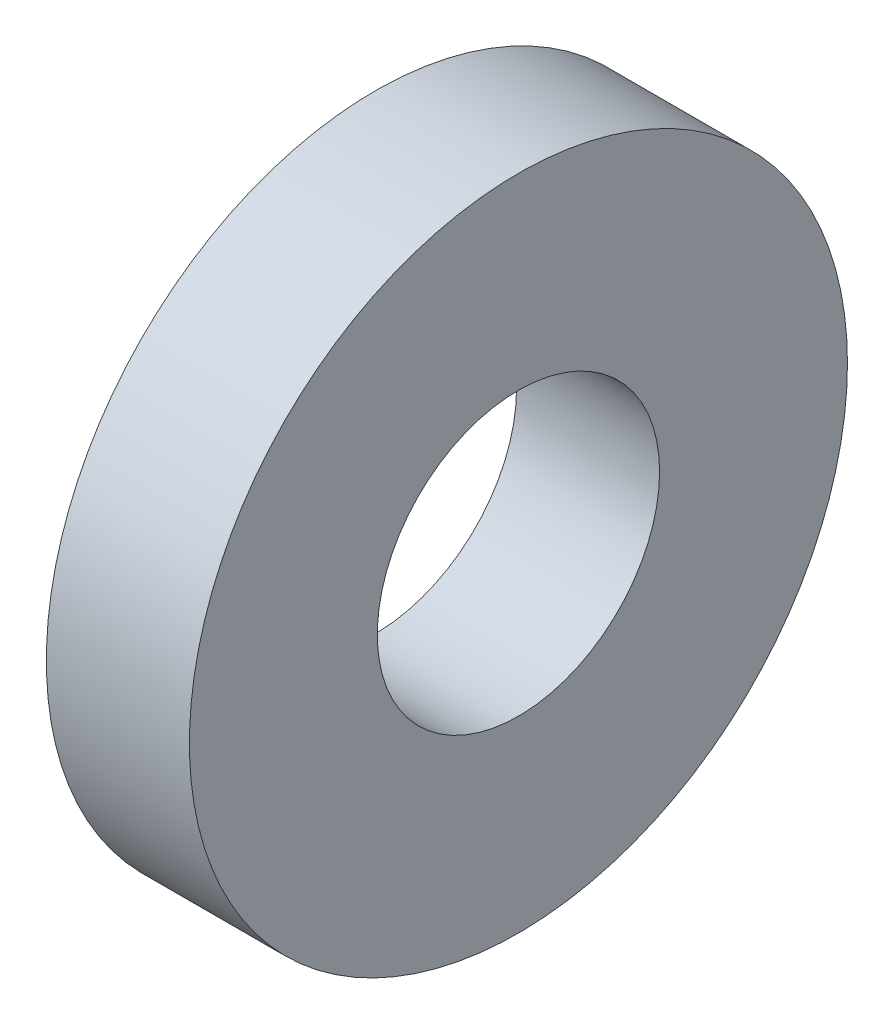
from build123d import *

# Parameters (mm, degrees)
SKETCH_1_R      = 3.45
SKETCH_1_R_2    = 1.48
EXTRUDE_1_DEPTH = 1.5


with BuildPart() as part:
    # 草图1 → 凸台-拉伸1 (new body)
    with BuildSketch(Plane(origin=(0, 0, 0), x_dir=(0, 0, -1), z_dir=(1, 0, 0))):
        Circle(SKETCH_1_R)
        Circle(SKETCH_1_R_2, mode=Mode.SUBTRACT)
    extrude(amount=EXTRUDE_1_DEPTH)


solid = part.part
